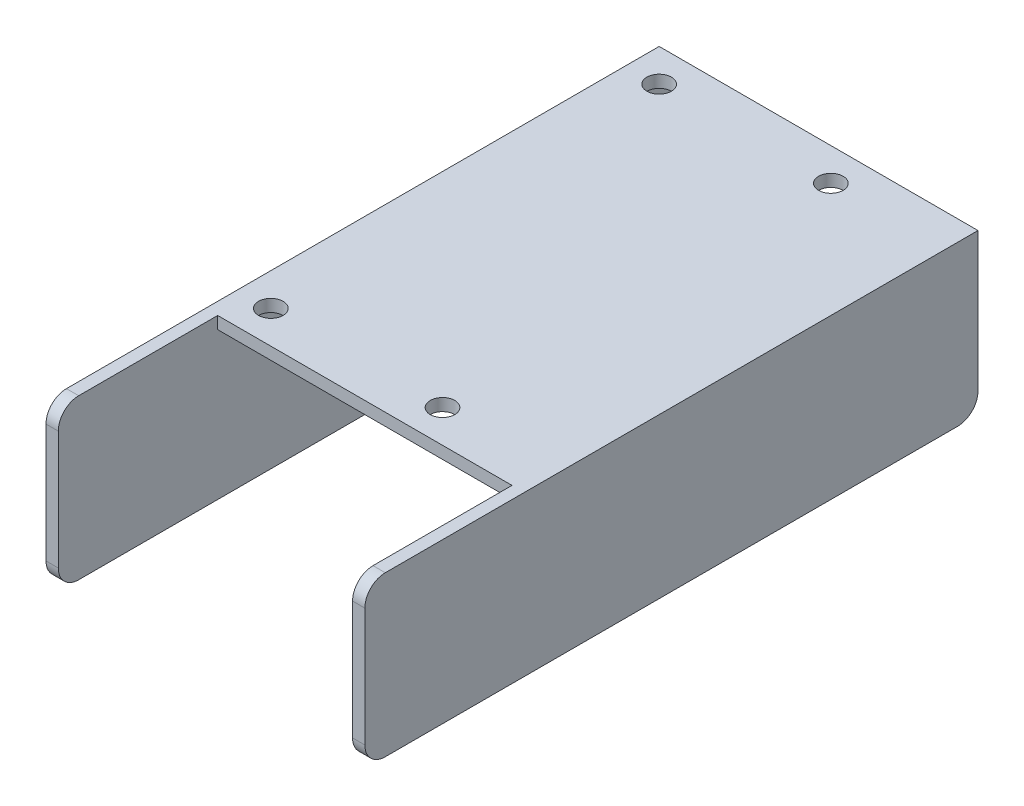
from build123d import *

# Parameters (mm, degrees)
BOSS_EXTRUDE1_DEPTH = 19.5
SHELL1_T            = -3
SKETCH2_W           = 36
SKETCH2_H           = 39
CUT_EXTRUDE1_DEPTH  = 3
FILLET1_R           = 5
CUT_EXTRUDE2_REACH  = 41
SKETCH3_R           = 3


with BuildPart() as part:
    # Sketch1 → Boss-Extrude1 (new body, symmetric)
    with BuildSketch(Plane(origin=(0, 0, 0), x_dir=(1, 0, 0), z_dir=(0, 1, 0))):
        Polygon((0, -36), (0, -75), (-36, -75), (-39, -75), (-39, 75), (0, 75), (0, 0), align=None)
    boss_extrude1 = extrude(amount=BOSS_EXTRUDE1_DEPTH, both=True)

    # Mirror1: Boss-Extrude1 across plane
    add(boss_extrude1.mirror(Plane(origin=(0, 0, 0), x_dir=(0, 0, 1), z_dir=(1, 0, 0))))

    # Shell1
    shell1_openings = [part.faces().sort_by_distance(p)[0] for p in [
        (0, 0, 75),
        (0, 0, -75),
        (0, -19.5, 0),
    ]]
    offset(amount=SHELL1_T, openings=shell1_openings, kind=Kind.INTERSECTION)

    # Sketch2 → Cut-Extrude1 (cut)
    with BuildSketch(Plane(origin=(0, 19.5, 0), x_dir=(1, 0, 0), z_dir=(0, 1, 0))):
        with Locations((-18, -55.5)):
            Rectangle(SKETCH2_W, SKETCH2_H)
    cut_extrude1 = extrude(amount=-CUT_EXTRUDE1_DEPTH, mode=Mode.SUBTRACT)

    # Mirror2: Cut-Extrude1 across plane
    add(cut_extrude1.mirror(Plane(origin=(0, 0, 0), x_dir=(0, 0, 1), z_dir=(1, 0, 0))), mode=Mode.SUBTRACT)

    # Fillet1
    fillet1_edges = [part.edges().sort_by_distance(p)[0] for p in [
        (-37.5, 19.5, 75),
        (-37.5, -19.5, -75),
        (37.5, -19.5, 75),
        (37.5, 19.5, 75),
        (-37.5, -19.5, 75),
        (37.5, -19.5, -75),
    ]]
    fillet(fillet1_edges, radius=FILLET1_R)

    # Sketch3 → Cut-Extrude2 (cut, up to next)
    with BuildSketch(Plane(origin=(0, 19.5, 0), x_dir=(1, 0, 0), z_dir=(0, 1, 0)), mode=Mode.PRIVATE) as cut_extrude2_sk1:
        with Locations((-31, 67)):
            Circle(SKETCH3_R)
    cut_extrude2_tool1 = extrude(cut_extrude2_sk1.sketch, amount=-CUT_EXTRUDE2_REACH, mode=Mode.PRIVATE) & part.part
    add(cut_extrude2_tool1.solids().sort_by_distance((-31, 19.5, -67))[0], mode=Mode.SUBTRACT)
    # Sketch3 → Cut-Extrude2 (cut, up to next)
    with BuildSketch(Plane(origin=(0, 19.5, 0), x_dir=(1, 0, 0), z_dir=(0, 1, 0)), mode=Mode.PRIVATE) as cut_extrude2_sk2:
        with Locations((-31, -28)):
            Circle(SKETCH3_R)
    cut_extrude2_tool2 = extrude(cut_extrude2_sk2.sketch, amount=-CUT_EXTRUDE2_REACH, mode=Mode.PRIVATE) & part.part
    add(cut_extrude2_tool2.solids().sort_by_distance((-31, 19.5, 28))[0], mode=Mode.SUBTRACT)
    # Sketch3 → Cut-Extrude2 (cut, up to next)
    with BuildSketch(Plane(origin=(0, 19.5, 0), x_dir=(1, 0, 0), z_dir=(0, 1, 0)), mode=Mode.PRIVATE) as cut_extrude2_sk3:
        with Locations((11, -28)):
            Circle(SKETCH3_R)
    cut_extrude2_tool3 = extrude(cut_extrude2_sk3.sketch, amount=-CUT_EXTRUDE2_REACH, mode=Mode.PRIVATE) & part.part
    add(cut_extrude2_tool3.solids().sort_by_distance((11, 19.5, 28))[0], mode=Mode.SUBTRACT)
    # Sketch3 → Cut-Extrude2 (cut, up to next)
    with BuildSketch(Plane(origin=(0, 19.5, 0), x_dir=(1, 0, 0), z_dir=(0, 1, 0)), mode=Mode.PRIVATE) as cut_extrude2_sk4:
        with Locations((11, 67)):
            Circle(SKETCH3_R)
    cut_extrude2_tool4 = extrude(cut_extrude2_sk4.sketch, amount=-CUT_EXTRUDE2_REACH, mode=Mode.PRIVATE) & part.part
    add(cut_extrude2_tool4.solids().sort_by_distance((11, 19.5, -67))[0], mode=Mode.SUBTRACT)


solid = part.part
